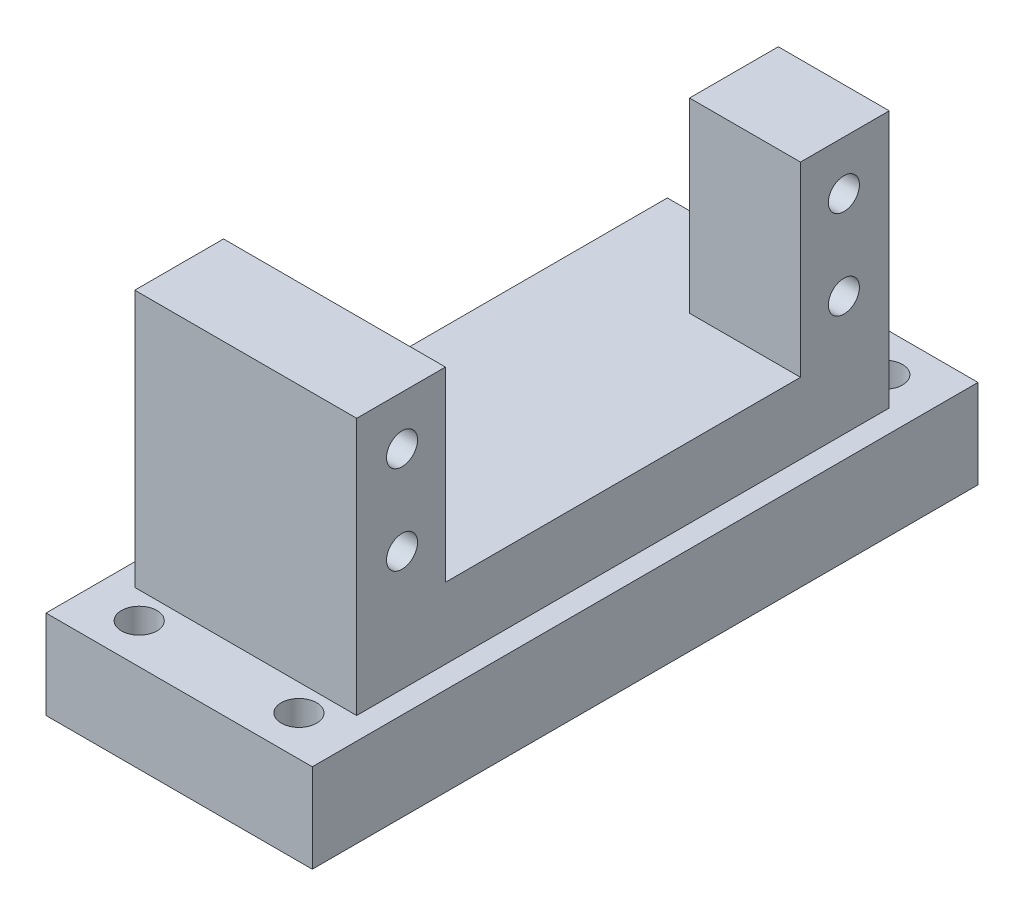
from build123d import *

# Parameters (mm, degrees)
SKETCH1_W           = 25
SKETCH1_H           = 60
BOSS_EXTRUDE1_DEPTH = 8
SKETCH2_W           = 25
SKETCH2_H           = 10
SKETCH2_W_2         = 12.5
BOSS_EXTRUDE2_DEPTH = 21
CUT_EXTRUDE1_REACH  = 27
SKETCH3_R           = 1.75
SKETCH6_W           = 30
SKETCH6_H           = 75
BOSS_EXTRUDE3_DEPTH = 10
CUT_EXTRUDE4_REACH  = 12
SKETCH7_R           = 2


with BuildPart() as part:
    # Sketch1 → Boss-Extrude1 (new body)
    with BuildSketch(Plane(origin=(0, 0, 0), x_dir=(1, 0, 0), z_dir=(0, 1, 0))):
        Rectangle(SKETCH1_W, SKETCH1_H)
    extrude(amount=BOSS_EXTRUDE1_DEPTH)

    # Sketch2 → Boss-Extrude2 (add)
    with BuildSketch(Plane(origin=(0, 8, 0), x_dir=(1, 0, 0), z_dir=(0, 1, 0))):
        with Locations((0, -25)):
            Rectangle(SKETCH2_W, SKETCH2_H)
        with Locations((6.25, 25)):
            Rectangle(SKETCH2_W_2, SKETCH2_H)
    extrude(amount=BOSS_EXTRUDE2_DEPTH)

    # Sketch3 → Cut-Extrude1 (cut, up to next)
    with BuildSketch(Plane.ZY.offset(-12.5), mode=Mode.PRIVATE) as cut_extrude1_sk1:
        with Locations((-24.89, 23.47)):
            Circle(SKETCH3_R)
    cut_extrude1_tool1 = extrude(cut_extrude1_sk1.sketch, amount=CUT_EXTRUDE1_REACH, mode=Mode.PRIVATE) & part.part
    add(cut_extrude1_tool1.solids().sort_by_distance((12.5, 23.47, -24.89))[0], mode=Mode.SUBTRACT)
    # Sketch3 → Cut-Extrude1 (cut, up to next)
    with BuildSketch(Plane.ZY.offset(-12.5), mode=Mode.PRIVATE) as cut_extrude1_sk2:
        with Locations((-24.89, 13.47)):
            Circle(SKETCH3_R)
    cut_extrude1_tool2 = extrude(cut_extrude1_sk2.sketch, amount=CUT_EXTRUDE1_REACH, mode=Mode.PRIVATE) & part.part
    add(cut_extrude1_tool2.solids().sort_by_distance((12.5, 13.47, -24.89))[0], mode=Mode.SUBTRACT)
    # Sketch3 → Cut-Extrude1 (cut, up to next)
    with BuildSketch(Plane.ZY.offset(-12.5), mode=Mode.PRIVATE) as cut_extrude1_sk3:
        with Locations((24.89, 23.47)):
            Circle(SKETCH3_R)
    cut_extrude1_tool3 = extrude(cut_extrude1_sk3.sketch, amount=CUT_EXTRUDE1_REACH, mode=Mode.PRIVATE) & part.part
    add(cut_extrude1_tool3.solids().sort_by_distance((12.5, 23.47, 24.89))[0], mode=Mode.SUBTRACT)
    # Sketch3 → Cut-Extrude1 (cut, up to next)
    with BuildSketch(Plane.ZY.offset(-12.5), mode=Mode.PRIVATE) as cut_extrude1_sk4:
        with Locations((24.89, 13.47)):
            Circle(SKETCH3_R)
    cut_extrude1_tool4 = extrude(cut_extrude1_sk4.sketch, amount=CUT_EXTRUDE1_REACH, mode=Mode.PRIVATE) & part.part
    add(cut_extrude1_tool4.solids().sort_by_distance((12.5, 13.47, 24.89))[0], mode=Mode.SUBTRACT)

    # Sketch6 → Boss-Extrude3 (add)
    with BuildSketch(Plane.XZ):
        Rectangle(SKETCH6_W, SKETCH6_H)
    extrude(amount=BOSS_EXTRUDE3_DEPTH)

    # Sketch7 → Cut-Extrude4 (cut, up to next)
    with BuildSketch(Plane(origin=(0, 0, 0), x_dir=(1, 0, 0), z_dir=(0, 1, 0)), mode=Mode.PRIVATE) as cut_extrude4_sk1:
        with Locations((9, 33)):
            Circle(SKETCH7_R)
    cut_extrude4_tool1 = extrude(cut_extrude4_sk1.sketch, amount=-CUT_EXTRUDE4_REACH, mode=Mode.PRIVATE) & part.part
    add(cut_extrude4_tool1.solids().sort_by_distance((9, 0, -33))[0], mode=Mode.SUBTRACT)
    # Sketch7 → Cut-Extrude4 (cut, up to next)
    with BuildSketch(Plane(origin=(0, 0, 0), x_dir=(1, 0, 0), z_dir=(0, 1, 0)), mode=Mode.PRIVATE) as cut_extrude4_sk2:
        with Locations((-9, 33)):
            Circle(SKETCH7_R)
    cut_extrude4_tool2 = extrude(cut_extrude4_sk2.sketch, amount=-CUT_EXTRUDE4_REACH, mode=Mode.PRIVATE) & part.part
    add(cut_extrude4_tool2.solids().sort_by_distance((-9, 0, -33))[0], mode=Mode.SUBTRACT)
    # Sketch7 → Cut-Extrude4 (cut, up to next)
    with BuildSketch(Plane(origin=(0, 0, 0), x_dir=(1, 0, 0), z_dir=(0, 1, 0)), mode=Mode.PRIVATE) as cut_extrude4_sk3:
        with Locations((-9, -33)):
            Circle(SKETCH7_R)
    cut_extrude4_tool3 = extrude(cut_extrude4_sk3.sketch, amount=-CUT_EXTRUDE4_REACH, mode=Mode.PRIVATE) & part.part
    add(cut_extrude4_tool3.solids().sort_by_distance((-9, 0, 33))[0], mode=Mode.SUBTRACT)
    # Sketch7 → Cut-Extrude4 (cut, up to next)
    with BuildSketch(Plane(origin=(0, 0, 0), x_dir=(1, 0, 0), z_dir=(0, 1, 0)), mode=Mode.PRIVATE) as cut_extrude4_sk4:
        with Locations((9, -33)):
            Circle(SKETCH7_R)
    cut_extrude4_tool4 = extrude(cut_extrude4_sk4.sketch, amount=-CUT_EXTRUDE4_REACH, mode=Mode.PRIVATE) & part.part
    add(cut_extrude4_tool4.solids().sort_by_distance((9, 0, 33))[0], mode=Mode.SUBTRACT)


solid = part.part
